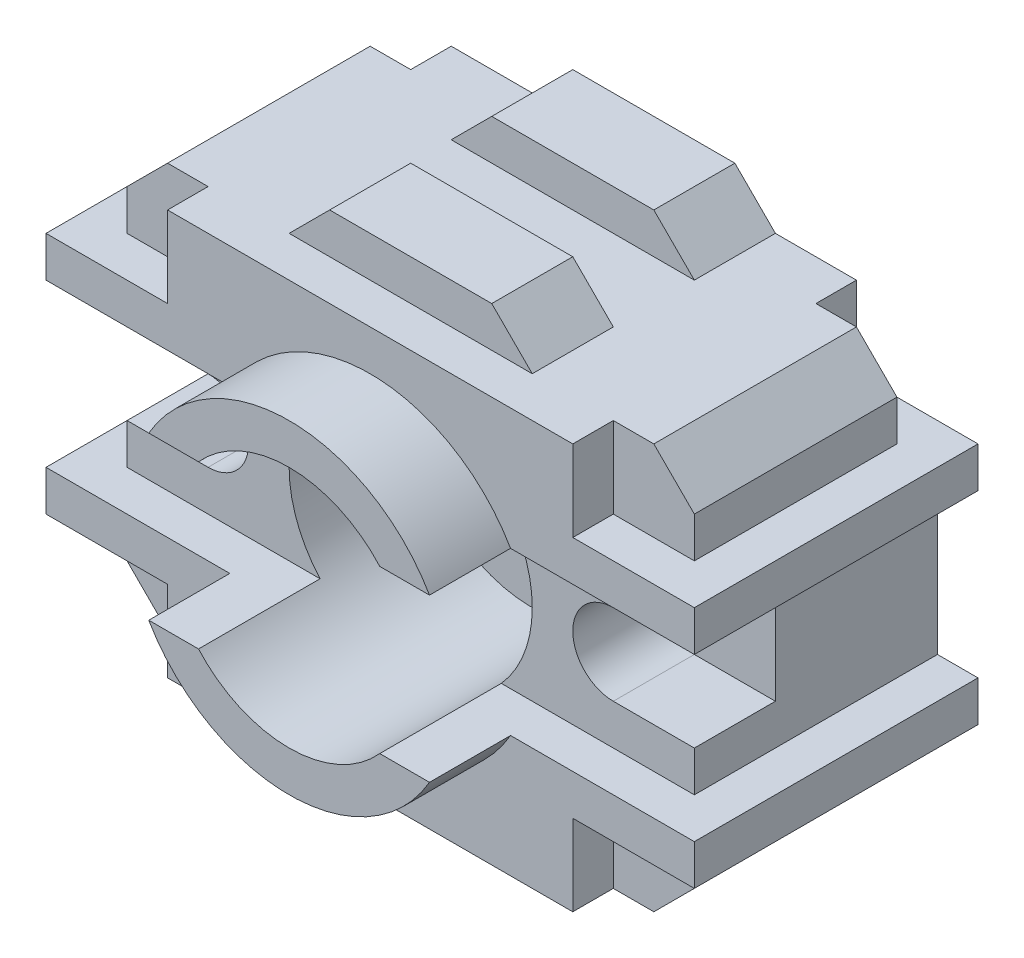
from build123d import *

# Parameters (mm, degrees)
BOSS_EXTRUDE2_DEPTH  = 30
BOSS_EXTRUDE3_DEPTH  = 10
BOSS_EXTRUDE4_DEPTH  = 10
BOSS_EXTRUDE7_DEPTH  = 5
CUT_EXTRUDE9_DEPTH   = 10
SKETCH13_R           = 2.5
CUT_EXTRUDE10_DEPTH  = 190
SKETCH14_R           = 15
CUT_EXTRUDE12_DEPTH  = 15
CUT_EXTRUDE13_DEPTH  = 5
BOSS_EXTRUDE8_DEPTH  = 10
SKETCH17_R           = 5
CUT_EXTRUDE15_DEPTH  = 15
CUT_EXTRUDE16_DEPTH  = 5
SKETCH19_W           = 30
SKETCH19_H           = 5
BOSS_EXTRUDE9_DEPTH  = 5
SKETCH20_W           = 30
SKETCH20_H           = 5
BOSS_EXTRUDE10_DEPTH = 5


with BuildPart() as part:
    # Sketch2 → Boss-Extrude2 (new body)
    with BuildSketch(Plane.XY):
        Polygon((-70, 40), (-65, 45), (-5, 45), (0, 40), (0, 0), (-5, -5), (-65, -5), (-70, 0), align=None)
    extrude(amount=BOSS_EXTRUDE2_DEPTH)

    # Sketch4 → Boss-Extrude3 (add)
    with BuildSketch(Plane.XY.offset(30)):
        Polygon((-50, 45), (-45, 50), (-25, 50), (-20, 45), align=None)
    extrude(amount=-BOSS_EXTRUDE3_DEPTH)

    # Sketch5 → Boss-Extrude4 (add)
    with BuildSketch(Plane(origin=(0, 0, 0), x_dir=(-1, 0, 0), z_dir=(0, 0, -1))):
        Polygon((20, 45), (25, 50), (45, 50), (50, 45), align=None)
    extrude(amount=-BOSS_EXTRUDE4_DEPTH)

    # Sketch6 → Boss-Extrude7 (add)
    with BuildSketch(Plane.XY.offset(30)):
        Polygon((-75, 30), (5, 30), (5, 35), (-10, 35), (-10, 45), (-60, 45), (-60, 35), (-75, 35), align=None)
        Polygon((-75, 10), (5, 10), (5, 5), (-10, 5), (-10, -5), (-60, -5), (-60, 5), (-75, 5), align=None)
    extrude(amount=BOSS_EXTRUDE7_DEPTH)

    # Sketch12 → Cut-Extrude9 (cut)
    with BuildSketch(Plane.XY.offset(30)):
        with BuildLine():
            Line((-70, 25), (-60, 25))
            ThreePointArc((-60, 25), (-55, 20), (-60, 15))
            Line((-60, 15), (-70, 15))
            Line((-70, 15), (-70, 25))
        make_face()
        with BuildLine():
            Line((0, 15), (-10, 15))
            ThreePointArc((-10, 15), (-15, 20), (-10, 25))
            Line((-10, 25), (0, 25))
            Line((0, 25), (0, 15))
        make_face()
    extrude(amount=-CUT_EXTRUDE9_DEPTH, mode=Mode.SUBTRACT)

    # Sketch13 → Cut-Extrude10 (cut)
    with BuildSketch(Plane.XY.offset(20)):
        with Locations((-60, 20)):
            Circle(SKETCH13_R)
        with Locations((-10, 20)):
            Circle(SKETCH13_R)
    extrude(amount=-CUT_EXTRUDE10_DEPTH, mode=Mode.SUBTRACT)

    # Sketch14 → Cut-Extrude12 (cut)
    with BuildSketch(Plane.XY.offset(30)):
        with Locations((-35, 20)):
            Circle(SKETCH14_R)
    extrude(amount=-CUT_EXTRUDE12_DEPTH, mode=Mode.SUBTRACT)

    # Sketch15 → Cut-Extrude13 (cut)
    with BuildSketch(Plane.XY.offset(35)):
        with BuildLine():
            Line((-46.180339887, 10), (-23.819660113, 10))
            ThreePointArc((-23.819660113, 10), (-35, 5), (-46.180339887, 10))
        make_face()
        with BuildLine():
            Line((-46.180339887, 30), (-23.819660113, 30))
            ThreePointArc((-23.819660113, 30), (-35, 35), (-46.180339887, 30))
        make_face()
    extrude(amount=-CUT_EXTRUDE13_DEPTH, mode=Mode.SUBTRACT)

    # Sketch16 → Boss-Extrude8 (add)
    with BuildSketch(Plane.XY.offset(35)):
        with BuildLine():
            ThreePointArc((-17.679491924, 10), (-35, 0), (-52.320508076, 10))
            Line((-52.320508076, 10), (-46.180339887, 10))
            ThreePointArc((-46.180339887, 10), (-35, 5), (-23.819660113, 10))
            Line((-23.819660113, 10), (-17.679491924, 10))
        make_face()
        with BuildLine():
            Line((-52.320508076, 30), (-46.180339887, 30))
            ThreePointArc((-46.180339887, 30), (-35, 35), (-23.819660113, 30))
            Line((-23.819660113, 30), (-17.679491924, 30))
            ThreePointArc((-17.679491924, 30), (-35, 40), (-52.320508076, 30))
        make_face()
    extrude(amount=BOSS_EXTRUDE8_DEPTH)

    # Sketch17 → Cut-Extrude15 (cut)
    with BuildSketch(Plane.XY.offset(15)):
        with Locations((-35, 20)):
            Circle(SKETCH17_R)
    extrude(amount=-CUT_EXTRUDE15_DEPTH, mode=Mode.SUBTRACT)

    # Sketch18 → Cut-Extrude16 (cut)
    with BuildSketch(Plane(origin=(0, 0, 0), x_dir=(-1, 0, 0), z_dir=(0, 0, -1))):
        Polygon((5, -5), (10, -5), (10, 5), (0, 5), (0, 0), align=None)
        Polygon((0, 40), (0, 35), (10, 35), (10, 45), (5, 45), align=None)
        Polygon((60, 45), (60, 35), (70, 35), (70, 40), (65, 45), align=None)
        Polygon((70, 0), (70, 5), (60, 5), (60, -5), (65, -5), align=None)
    extrude(amount=-CUT_EXTRUDE16_DEPTH, mode=Mode.SUBTRACT)

    # Sketch19 → Boss-Extrude9 (add)
    with BuildSketch(Plane.ZY.offset(70)):
        with Locations((15, 32.5)):
            Rectangle(SKETCH19_W, SKETCH19_H)
        with Locations((15, 7.5)):
            Rectangle(SKETCH19_W, SKETCH19_H)
    extrude(amount=BOSS_EXTRUDE9_DEPTH)

    # Sketch20 → Boss-Extrude10 (add)
    with BuildSketch(Plane(origin=(0, 0, 0), x_dir=(0, 0, -1), z_dir=(1, 0, 0))):
        with Locations((-15, 32.5)):
            Rectangle(SKETCH20_W, SKETCH20_H)
        with Locations((-15, 7.5)):
            Rectangle(SKETCH20_W, SKETCH20_H)
    extrude(amount=BOSS_EXTRUDE10_DEPTH)


solid = part.part
